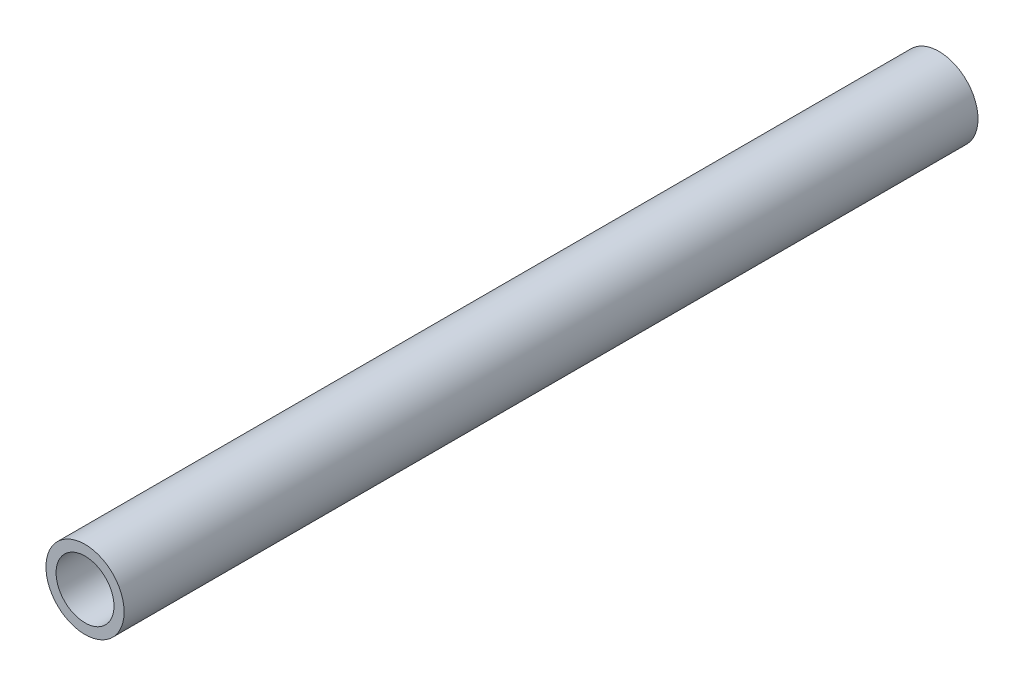
from build123d import *

# Parameters (mm, degrees)
SKETCH1_R                = 10.668
SKETCH1_R_2              = 7.8994
EXTRUDE_THIN1_DEPTH      = 141.5
EXTRUDE_THIN1_DEPTH_BACK = 91.5


with BuildPart() as part:
    # Sketch1 → Extrude-Thin1 (new body, two sides)
    with BuildSketch(Plane.XY) as extrude_thin1_sk:
        Circle(SKETCH1_R)
        Circle(SKETCH1_R_2, mode=Mode.SUBTRACT)
    extrude(amount=EXTRUDE_THIN1_DEPTH)
    extrude(extrude_thin1_sk.sketch, amount=-EXTRUDE_THIN1_DEPTH_BACK)


solid = part.part
